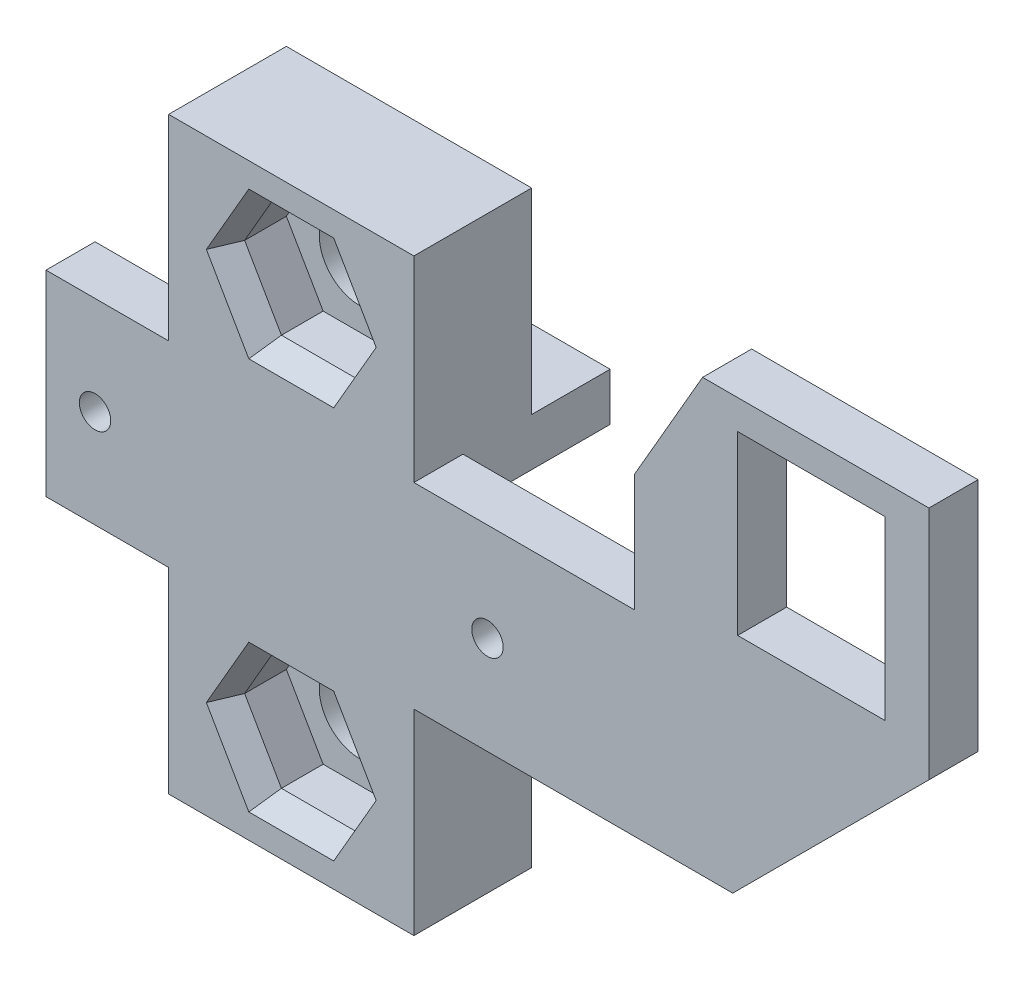
from build123d import *

# Parameters (mm, degrees)
SKETCH2_W                = 25
SKETCH2_H                = 20
BOSS_EXTRUDE1_DEPTH      = 30
SKETCH3_W                = 20.25
SKETCH3_H                = 10.25
CUT_EXTRUDE1_DEPTH       = 26
SKETCH4_W                = 50
SKETCH4_H                = 20
BOSS_EXTRUDE2_DEPTH      = 5
SKETCH6_R                = 1.6
CUT_EXTRUDE2_DEPTH       = 36
SKETCH9_W                = 5
SKETCH9_H                = 20
BOSS_EXTRUDE3_DEPTH      = 40
BOSS_EXTRUDE5_START      = -5
SKETCH14_W               = 30
SKETCH14_H               = 24
BOSS_EXTRUDE5_DEPTH      = 5
SKETCH19_W               = 15
SKETCH19_H               = 18
CUT_EXTRUDE5_DEPTH       = 36
CHAMFER1_SIZE            = 12
CHAMFER1_SIZE2           = 6.92820323
CHAMFER2_SIZE            = 20
SKETCH20_W               = 25
SKETCH20_H               = 9
BOSS_EXTRUDE6_DEPTH      = 20
BOSS_EXTRUDE6_DEPTH_BACK = 40
SKETCH21_W               = 25
SKETCH21_H               = 20
CUT_EXTRUDE6_DEPTH       = 15
CUT_EXTRUDE7_DEPTH       = 7
SKETCH23_W               = 25
SKETCH23_H               = 20
BOSS_EXTRUDE7_DEPTH      = 3
SKETCH24_R               = 4.15
CUT_EXTRUDE8_DEPTH       = 14
CHAMFER3_SIZE            = 1
CHAMFER3_SIZE2           = 2.747477419


with BuildPart() as part:
    # Sketch2 → Boss-Extrude1 (new body)
    with BuildSketch(Plane.XY):
        Rectangle(SKETCH2_W, SKETCH2_H)
    extrude(amount=BOSS_EXTRUDE1_DEPTH)

    # Sketch3 → Cut-Extrude1 (cut, through all)
    with BuildSketch(Plane.ZY.offset(12.5)):
        with Locations((15, 0)):
            Rectangle(SKETCH3_W, SKETCH3_H)
    extrude(amount=-CUT_EXTRUDE1_DEPTH, mode=Mode.SUBTRACT)

    # Sketch4 → Boss-Extrude2 (add)
    with BuildSketch(Plane.XY.offset(30)):
        Rectangle(SKETCH4_W, SKETCH4_H)
    extrude(amount=BOSS_EXTRUDE2_DEPTH)

    # Sketch6 → Cut-Extrude2 (cut, through all)
    with BuildSketch(Plane.XY.offset(35)):
        with Locations((-20, 0)):
            Circle(SKETCH6_R)
        with Locations((20, 0)):
            Circle(SKETCH6_R)
    extrude(amount=-CUT_EXTRUDE2_DEPTH, mode=Mode.SUBTRACT)

    # Sketch9 → Boss-Extrude3 (add)
    with BuildSketch(Plane(origin=(25, 0, 0), x_dir=(0, 0, -1), z_dir=(1, 0, 0))):
        with Locations((-32.5, 0)):
            Rectangle(SKETCH9_W, SKETCH9_H)
    extrude(amount=BOSS_EXTRUDE3_DEPTH)

    # Sketch14 → Boss-Extrude5 (add)
    with BuildSketch(Plane.XY.offset(35).offset(BOSS_EXTRUDE5_START)):
        with Locations((50, 22)):
            Rectangle(SKETCH14_W, SKETCH14_H)
    extrude(amount=BOSS_EXTRUDE5_DEPTH)

    # Sketch19 → Cut-Extrude5 (cut, through all)
    with BuildSketch(Plane.XY.offset(35)):
        with Locations((53, 22)):
            Rectangle(SKETCH19_W, SKETCH19_H)
    extrude(amount=-CUT_EXTRUDE5_DEPTH, mode=Mode.SUBTRACT)

    # Chamfer1
    chamfer1_edges = [part.edges().sort_by_distance(p)[0] for p in [
        (35, 34, 32.5),
    ]]
    chamfer1_side = [part.faces().sort_by_distance(p)[0] for p in [
        (35, 22, 32.5),
    ]]
    chamfer(chamfer1_edges, length=CHAMFER1_SIZE, length2=CHAMFER1_SIZE2, reference=chamfer1_side[0])

    # Chamfer2
    chamfer2_edges = [part.edges().sort_by_distance(p)[0] for p in [
        (65, -10, 32.5),
    ]]
    chamfer(chamfer2_edges, length=CHAMFER2_SIZE)

    # Sketch20 → Boss-Extrude6 (add, two sides)
    with BuildSketch(Plane(origin=(0, 10, 0), x_dir=(1, 0, 0), z_dir=(0, 1, 0))) as boss_extrude6_sk:
        with Locations((0, -30.5)):
            Rectangle(SKETCH20_W, SKETCH20_H)
    extrude(amount=BOSS_EXTRUDE6_DEPTH)
    extrude(boss_extrude6_sk.sketch, amount=-BOSS_EXTRUDE6_DEPTH_BACK)

    # Sketch21 → Cut-Extrude6 (cut)
    with BuildSketch(Plane(origin=(0, 0, 0), x_dir=(-1, 0, 0), z_dir=(0, 0, -1))):
        Rectangle(SKETCH21_W, SKETCH21_H)
    extrude(amount=-CUT_EXTRUDE6_DEPTH, mode=Mode.SUBTRACT)

    # Sketch22 → Cut-Extrude7 (cut)
    with BuildSketch(Plane.XY.offset(35)):
        Polygon((7.5, 20), (3.75, 26.495190528), (-3.75, 26.495190528), (-7.5, 20), (-3.75, 13.504809472), (3.75, 13.504809472), align=None)
        Polygon((7.5, -20), (3.75, -13.504809472), (-3.75, -13.504809472), (-7.5, -20), (-3.75, -26.495190528), (3.75, -26.495190528), align=None)
    extrude(amount=-CUT_EXTRUDE7_DEPTH, mode=Mode.SUBTRACT)

    # Sketch23 → Boss-Extrude7 (add)
    with BuildSketch(Plane(origin=(0, 0, 26), x_dir=(-1, 0, 0), z_dir=(0, 0, -1))):
        with Locations((0, 20)):
            Rectangle(SKETCH23_W, SKETCH23_H)
        with Locations((0, -20)):
            Rectangle(SKETCH23_W, SKETCH23_H)
    extrude(amount=BOSS_EXTRUDE7_DEPTH)

    # Sketch24 → Cut-Extrude8 (cut, through all)
    with BuildSketch(Plane.XY.offset(28)):
        with Locations((0, 20)):
            Circle(SKETCH24_R)
        with Locations((0, -20)):
            Circle(SKETCH24_R)
    extrude(amount=-CUT_EXTRUDE8_DEPTH, mode=Mode.SUBTRACT)

    # Chamfer3
    chamfer3_edges = [part.edges().sort_by_distance(p)[0] for p in [
        (5.625, 16.752404736, 35),
        (5.625, 23.247595264, 35),
        (0, 26.495190528, 35),
        (-5.625, 23.247595264, 35),
        (-5.625, 16.752404736, 35),
        (0, 13.504809472, 35),
        (5.625, -23.247595264, 35),
        (5.625, -16.752404736, 35),
        (0, -13.504809472, 35),
        (-5.625, -16.752404736, 35),
        (-5.625, -23.247595264, 35),
        (0, -26.495190528, 35),
    ]]
    chamfer3_side = [part.faces().sort_by_distance(p)[0] for p in [
        (16.470883445, 3.451620449, 35),
    ]]
    chamfer(chamfer3_edges, length=CHAMFER3_SIZE, length2=CHAMFER3_SIZE2, reference=chamfer3_side[0])


solid = part.part
